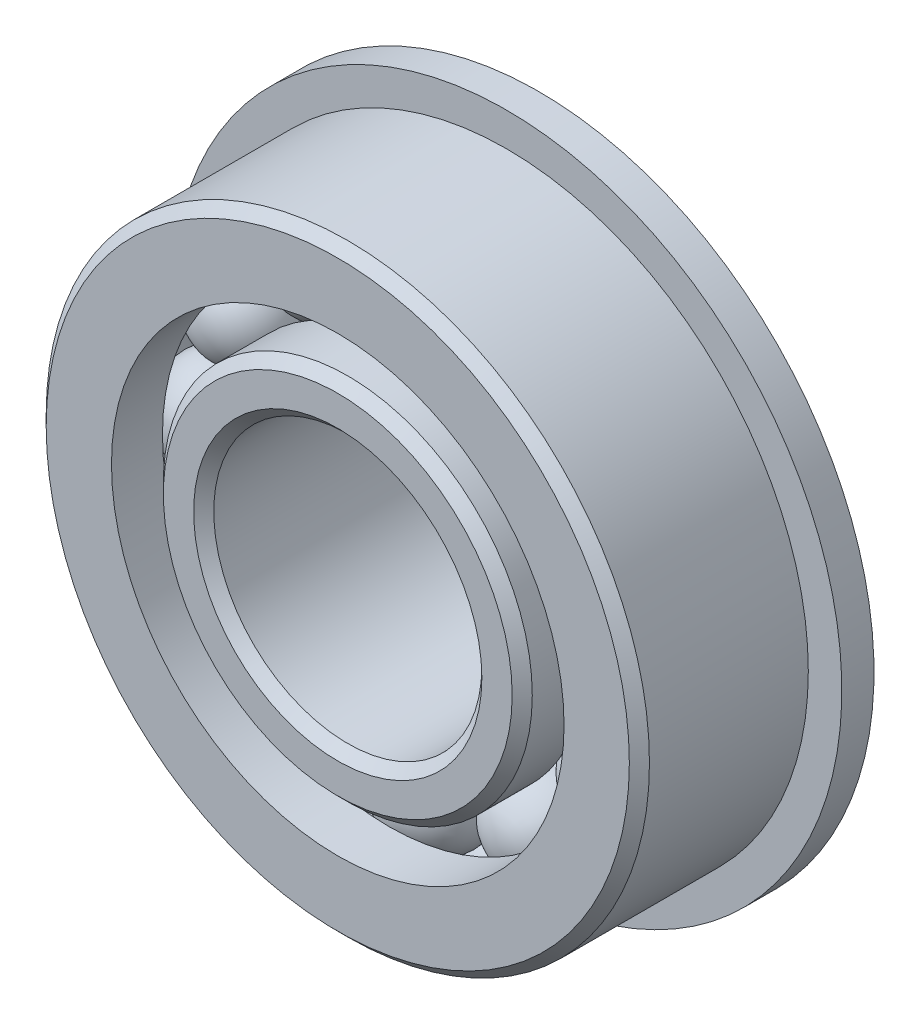
from build123d import *

# Parameters (mm, degrees)
SKETCH6_W         = 1.524
SKETCH6_H         = 5.1562
CIRPATTERN1_COUNT = 12


with BuildPart() as part:
    # Sketch1 → Revolve1 (revolve)
    with BuildSketch(Plane(origin=(0, 0, 0), x_dir=(0, 0, -1), z_dir=(1, 0, 0))):
        with BuildLine():
            Line((4.28625, 14.2875), (-4.28625, 14.2875))
            Line((-4.28625, 14.2875), (-4.7625, 13.81125))
            Line((-4.7625, 13.81125), (-4.7625, 10.7188))
            Line((-4.7625, 10.7188), (-2.347405282, 10.7188))
            ThreePointArc((-2.347405282, 10.7188), (0, 12.7), (2.347405282, 10.7188))
            Line((2.347405282, 10.7188), (4.7625, 10.7188))
            Line((4.7625, 10.7188), (4.7625, 13.81125))
            Line((4.7625, 13.81125), (4.28625, 14.2875))
        make_face()
    revolve(axis=Axis((0, 0, 4.7625), (0, 0, -1)))

    # Sketch6 → Revolve6 (revolve)
    with BuildSketch(Plane(origin=(0, 0, 0), x_dir=(0, 0, -1), z_dir=(1, 0, 0))):
        with Locations((4.0005, 13.2969)):
            Rectangle(SKETCH6_W, SKETCH6_H)
    revolve(axis=Axis((0, 0, -4.7625), (0, 0, 1)))


with BuildPart() as body_2:
    # Sketch3 → Revolve3 (revolve)
    with BuildSketch(Plane(origin=(0, 0, 0), x_dir=(0, 0, -1), z_dir=(1, 0, 0))):
        with BuildLine():
            Line((-4.7625, 6.82625), (-4.7625, 8.26135))
            Line((-4.7625, 8.26135), (-4.28625, 8.7376))
            Line((-4.28625, 8.7376), (-1.780538188, 8.7376))
            ThreePointArc((-1.780538188, 8.7376), (0, 7.9375), (1.780538188, 8.7376))
            Line((1.780538188, 8.7376), (5.88645, 8.7376))
            Line((5.88645, 8.7376), (6.3627, 8.26135))
            Line((6.3627, 8.26135), (6.3627, 6.82625))
            Line((6.3627, 6.82625), (5.88645, 6.35))
            Line((5.88645, 6.35), (-4.28625, 6.35))
            Line((-4.28625, 6.35), (-4.7625, 6.82625))
        make_face()
    revolve(axis=Axis((0, 0, 4.7625), (0, 0, -1)))


with BuildPart() as body_3:
    # Sketch4 → Revolve4 (revolve)
    with BuildSketch(Plane(origin=(0, 0, 0), x_dir=(0, 0, -1), z_dir=(1, 0, 0))):
        with BuildLine():
            Line((-2.38125, 10.31875), (2.38125, 10.31875))
            ThreePointArc((2.38125, 10.31875), (0, 12.7), (-2.38125, 10.31875))
        make_face()
    revolve(axis=Axis((0, 10.31875, 2.38125), (0, 0, -1)))


with BuildPart() as cirpattern1_1:
    # CirPattern1: pattern copy
    add(body_3.part.rotate(Axis((0, 0, -4.7625), (0, 0, 1)), 1 * 360 / CIRPATTERN1_COUNT))


with BuildPart() as cirpattern1_2:
    # CirPattern1: pattern copy
    add(body_3.part.rotate(Axis((0, 0, -4.7625), (0, 0, 1)), 2 * 360 / CIRPATTERN1_COUNT))


with BuildPart() as cirpattern1_3:
    # CirPattern1: pattern copy
    add(body_3.part.rotate(Axis((0, 0, -4.7625), (0, 0, 1)), 3 * 360 / CIRPATTERN1_COUNT))


with BuildPart() as cirpattern1_4:
    # CirPattern1: pattern copy
    add(body_3.part.rotate(Axis((0, 0, -4.7625), (0, 0, 1)), 4 * 360 / CIRPATTERN1_COUNT))


with BuildPart() as cirpattern1_5:
    # CirPattern1: pattern copy
    add(body_3.part.rotate(Axis((0, 0, -4.7625), (0, 0, 1)), 5 * 360 / CIRPATTERN1_COUNT))


with BuildPart() as cirpattern1_6:
    # CirPattern1: pattern copy
    add(body_3.part.rotate(Axis((0, 0, -4.7625), (0, 0, 1)), 6 * 360 / CIRPATTERN1_COUNT))


with BuildPart() as cirpattern1_7:
    # CirPattern1: pattern copy
    add(body_3.part.rotate(Axis((0, 0, -4.7625), (0, 0, 1)), 7 * 360 / CIRPATTERN1_COUNT))


with BuildPart() as cirpattern1_8:
    # CirPattern1: pattern copy
    add(body_3.part.rotate(Axis((0, 0, -4.7625), (0, 0, 1)), 8 * 360 / CIRPATTERN1_COUNT))


with BuildPart() as cirpattern1_9:
    # CirPattern1: pattern copy
    add(body_3.part.rotate(Axis((0, 0, -4.7625), (0, 0, 1)), 9 * 360 / CIRPATTERN1_COUNT))


with BuildPart() as cirpattern1_10:
    # CirPattern1: pattern copy
    add(body_3.part.rotate(Axis((0, 0, -4.7625), (0, 0, 1)), 10 * 360 / CIRPATTERN1_COUNT))


with BuildPart() as cirpattern1_11:
    # CirPattern1: pattern copy
    add(body_3.part.rotate(Axis((0, 0, -4.7625), (0, 0, 1)), 11 * 360 / CIRPATTERN1_COUNT))


solid = Compound([part.part, body_2.part, body_3.part, cirpattern1_1.part, cirpattern1_2.part, cirpattern1_3.part, cirpattern1_4.part, cirpattern1_5.part, cirpattern1_6.part, cirpattern1_7.part, cirpattern1_8.part, cirpattern1_9.part, cirpattern1_10.part, cirpattern1_11.part])
